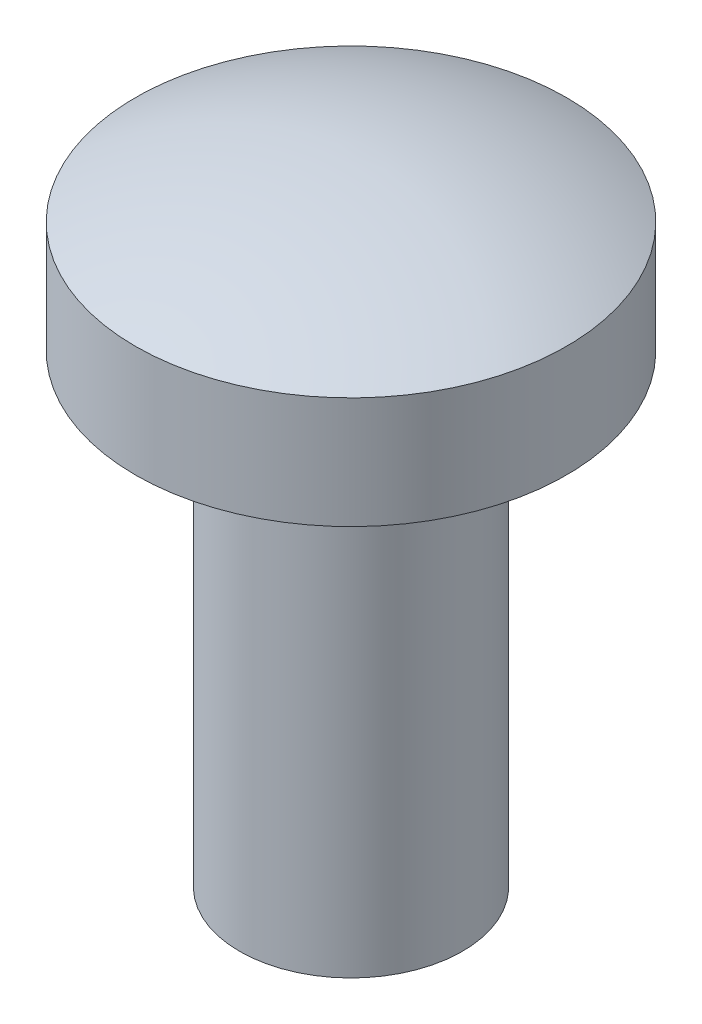
from build123d import *


with BuildPart() as part:
    # Sketch1 → Revolve1 (revolve)
    with BuildSketch(Plane(origin=(0, 0, 0), x_dir=(0, 0, -1), z_dir=(1, 0, 0)), mode=Mode.PRIVATE) as revolve1_sk:
        with BuildLine():
            Line((0, -3.175), (0, 1.1176))
            ThreePointArc((0, 1.1176), (0.757754842, 1.027441487), (1.4732, 0.762))
            Line((1.4732, 0.762), (1.4732, 0))
            Line((1.4732, 0), (0.762, 0))
            Line((0.762, 0), (0.762, -3.175))
            Line((0.762, -3.175), (0, -3.175))
        make_face()
    revolve(revolve1_sk.sketch.rotate(Axis((0, 64.907703711, 0), (0, -1, 0)), 180), axis=Axis((0, 64.907703711, 0), (0, -1, 0)))  # turned: the seam where the file's is


solid = part.part
